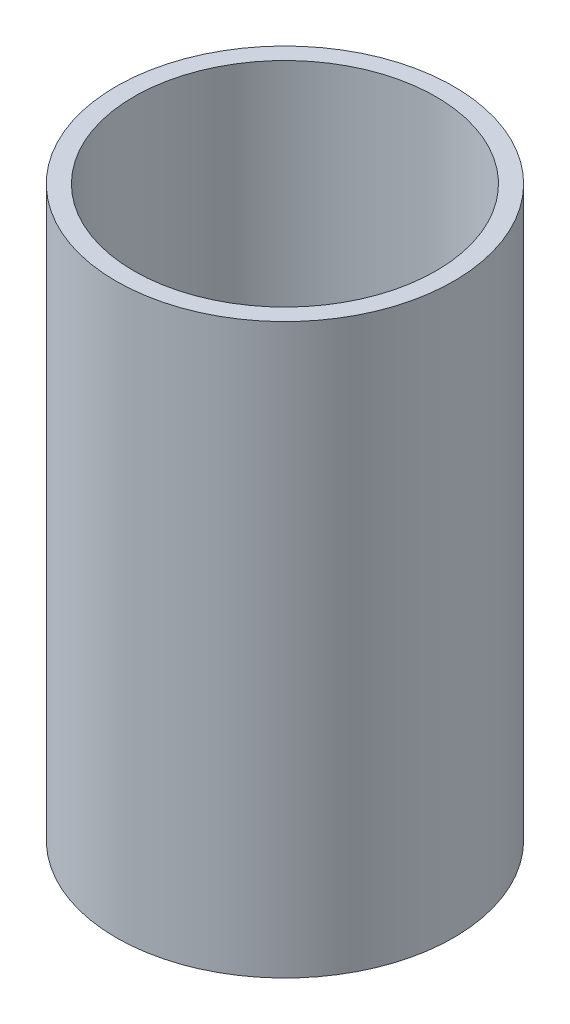
from build123d import *

# Parameters (mm, degrees)
SKETCH1_R           = 30.1625
SKETCH1_R_2         = 26.9875
BOSS_EXTRUDE1_DEPTH = 101.6


with BuildPart() as part:
    # Sketch1 → Boss-Extrude1 (new body)
    with BuildSketch(Plane(origin=(0, 0, 0), x_dir=(1, 0, 0), z_dir=(0, 1, 0))):
        Circle(SKETCH1_R)
        Circle(SKETCH1_R_2, mode=Mode.SUBTRACT)
    extrude(amount=BOSS_EXTRUDE1_DEPTH)


solid = part.part
